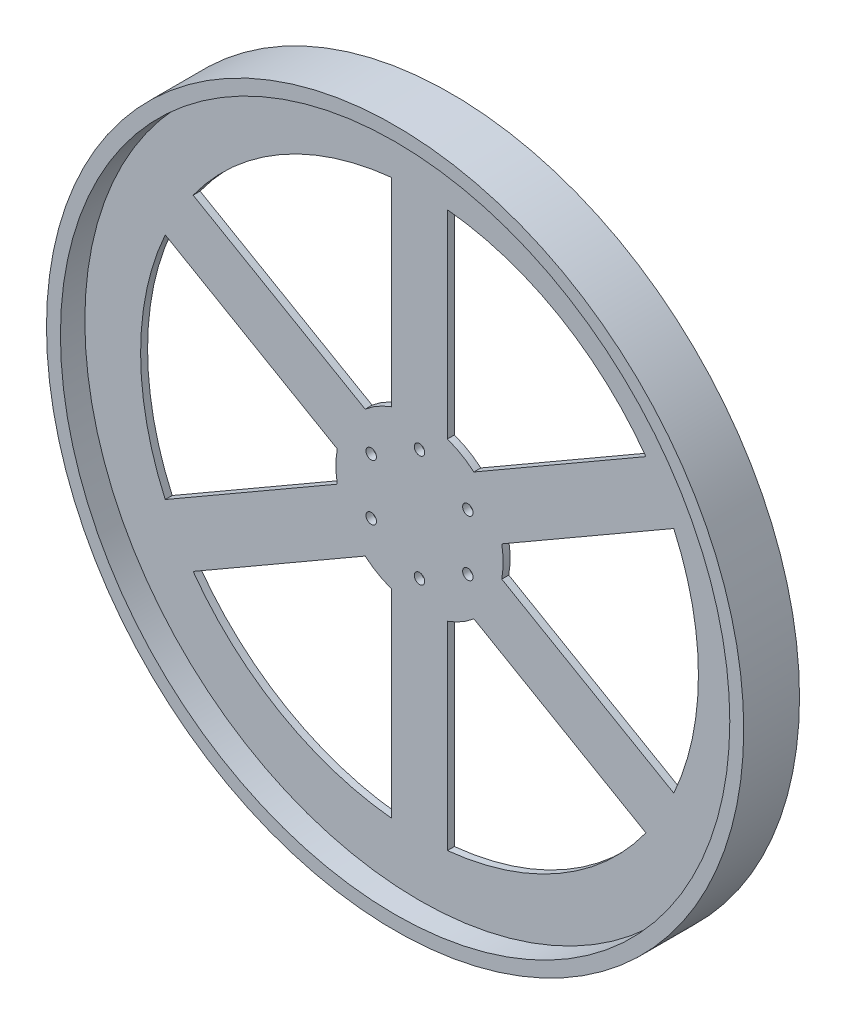
from build123d import *

# Parameters (mm, degrees)
BOSS_EXTRUDE1_DEPTH      = 3.175
BOSS_EXTRUDE1_DEPTH_BACK = 3.175
SKETCH2_R                = 304.8
BOSS_EXTRUDE2_DEPTH      = 25.4
BOSS_EXTRUDE2_DEPTH_BACK = 25.4
SKETCH5_R                = 317.5
SKETCH5_R_2              = 304.8
SKETCH6_R                = 4.7625
CUT_EXTRUDE4_DEPTH       = 450.921138229


with BuildPart() as part:
    # Sketch2 → Boss-Extrude1 (new, two sides: drawn at the far end of the back side and taken through both)
    with BuildSketch(Plane.XY.offset(-BOSS_EXTRUDE1_DEPTH_BACK)):
        Circle(SKETCH2_R)
        with BuildLine():
            ThreePointArc((25.4, -71.842048969), (38.1, -65.991135768), (49.517039467, -57.91806974))
            Line((49.517039467, -57.91806974), (206.167836833, -148.360449769))
            ThreePointArc((206.167836833, -148.360449769), (127, -219.970452561), (25.4, -252.726809025))
            Line((25.4, -252.726809025), (25.4, -71.842048969))
        make_face(mode=Mode.SUBTRACT)
        with BuildLine():
            ThreePointArc((-49.517039467, -57.91806974), (-38.1, -65.991135768), (-25.4, -71.842048969))
            Line((-25.4, -71.842048969), (-25.4, -252.726809025))
            ThreePointArc((-25.4, -252.726809025), (-127, -219.970452561), (-206.167836833, -148.360449769))
            Line((-206.167836833, -148.360449769), (-49.517039467, -57.91806974))
        make_face(mode=Mode.SUBTRACT)
        with BuildLine():
            ThreePointArc((-74.917039467, 13.923979228), (-76.2, 0), (-74.917039467, -13.923979228))
            Line((-74.917039467, -13.923979228), (-231.567836833, -104.366359256))
            ThreePointArc((-231.567836833, -104.366359256), (-254, 0), (-231.567836833, 104.366359256))
            Line((-231.567836833, 104.366359256), (-74.917039467, 13.923979228))
        make_face(mode=Mode.SUBTRACT)
        with BuildLine():
            ThreePointArc((-25.4, 71.842048969), (-38.1, 65.991135768), (-49.517039467, 57.91806974))
            Line((-49.517039467, 57.91806974), (-206.167836833, 148.360449769))
            ThreePointArc((-206.167836833, 148.360449769), (-127, 219.970452561), (-25.4, 252.726809025))
            Line((-25.4, 252.726809025), (-25.4, 71.842048969))
        make_face(mode=Mode.SUBTRACT)
        with BuildLine():
            ThreePointArc((49.517039467, 57.91806974), (38.1, 65.991135768), (25.4, 71.842048969))
            Line((25.4, 71.842048969), (25.4, 252.726809025))
            ThreePointArc((25.4, 252.726809025), (127, 219.970452561), (206.167836833, 148.360449769))
            Line((206.167836833, 148.360449769), (49.517039467, 57.91806974))
        make_face(mode=Mode.SUBTRACT)
        with BuildLine():
            Line((74.917039467, 13.923979228), (231.567836833, 104.366359256))
            ThreePointArc((231.567836833, 104.366359256), (254, 0), (231.567836833, -104.366359256))
            Line((231.567836833, -104.366359256), (74.917039467, -13.923979228))
            ThreePointArc((74.917039467, -13.923979228), (76.2, 0), (74.917039467, 13.923979228))
        make_face(mode=Mode.SUBTRACT)
    extrude(amount=BOSS_EXTRUDE1_DEPTH + BOSS_EXTRUDE1_DEPTH_BACK)

    # Sketch5 → Boss-Extrude2 (add, two sides: drawn at the far end of the back side and taken through both)
    with BuildSketch(Plane.XY.offset(-BOSS_EXTRUDE2_DEPTH_BACK)):
        Circle(SKETCH5_R)
        Circle(SKETCH5_R_2, mode=Mode.SUBTRACT)
    extrude(amount=BOSS_EXTRUDE2_DEPTH + BOSS_EXTRUDE2_DEPTH_BACK)

    # Sketch6 → Cut-Extrude4 (cut, through all)
    with BuildSketch(Plane.XY.offset(3.175)):
        with Locations((0, 50.8)):
            Circle(SKETCH6_R)
        with Locations((43.994090512, 25.4)):
            Circle(SKETCH6_R)
        with Locations((43.994090512, -25.4)):
            Circle(SKETCH6_R)
        with Locations((0, -50.8)):
            Circle(SKETCH6_R)
        with Locations((-43.994090512, -25.4)):
            Circle(SKETCH6_R)
        with Locations((-43.994090512, 25.4)):
            Circle(SKETCH6_R)
    extrude(amount=-CUT_EXTRUDE4_DEPTH, mode=Mode.SUBTRACT)


solid = part.part
